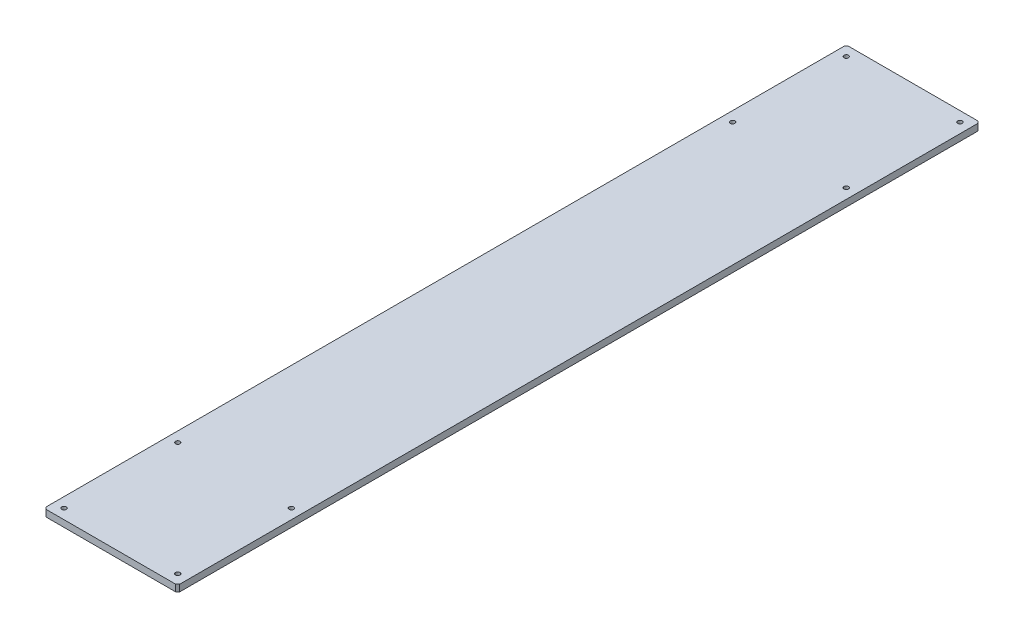
from build123d import *

# Parameters (mm, degrees)
SKETCH1_W              = 200
SKETCH1_H              = 1200
BOSS_EXTRUDE1_DEPTH    = 10
M8X1_25_TAPPED_HOLE1_D = 6.8
CHAMFER1_SIZE          = 3


with BuildPart() as part:
    # Sketch1 → Boss-Extrude1 (new body)
    with BuildSketch(Plane(origin=(0, 0, 0), x_dir=(1, 0, 0), z_dir=(0, 1, 0))):
        with Locations((100, 0)):
            Rectangle(SKETCH1_W, SKETCH1_H)
    extrude(amount=BOSS_EXTRUDE1_DEPTH)

    # M8x1.25 Tapped Hole1 (through all)
    with Locations(Plane(origin=(0, 10, 0), x_dir=(-1, 0, 0), z_dir=(0, 1, 0))):
        with Locations((-15, -585), (-15, -415), (-185, -415), (-185, -585), (-185, 415), (-185, 585), (-15, 585), (-15, 415)):
            Hole(M8X1_25_TAPPED_HOLE1_D / 2)

    # Chamfer1
    chamfer1_edges = [part.edges().sort_by_distance(p)[0] for p in [
        (0, 5, -600),
        (200, 5, -600),
        (200, 5, 600),
        (0, 5, 600),
    ]]
    chamfer(chamfer1_edges, length=CHAMFER1_SIZE)


solid = part.part
